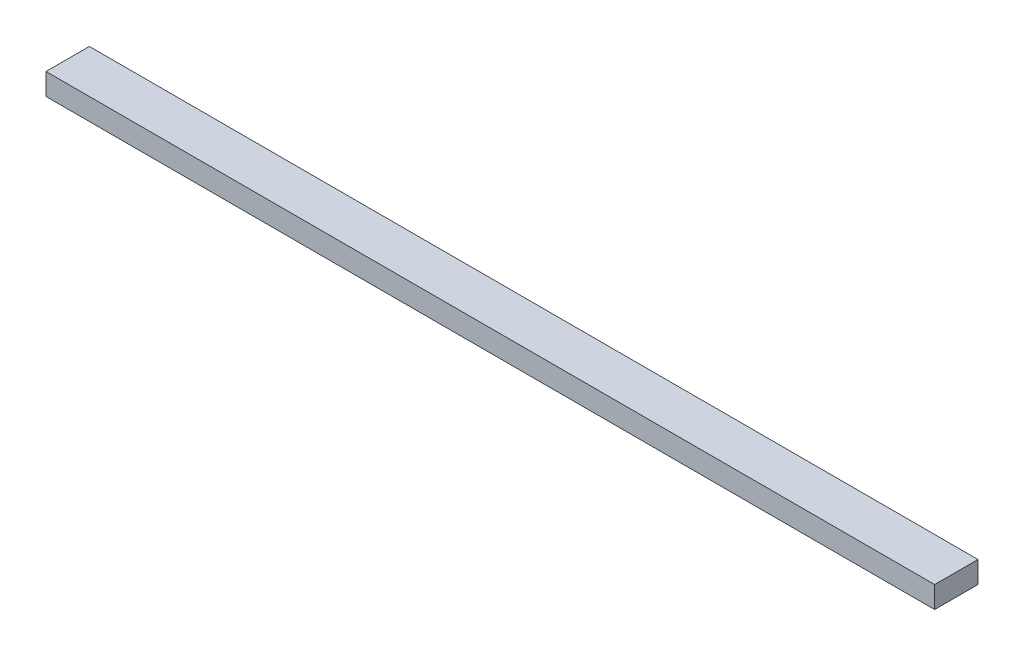
from build123d import *

# Parameters (mm, degrees)
SKETCH1_W           = 410
SKETCH1_H           = 20
BOSS_EXTRUDE1_DEPTH = 10


with BuildPart() as part:
    # Sketch1 → Boss-Extrude1 (new body)
    with BuildSketch(Plane(origin=(0, 0, 0), x_dir=(1, 0, 0), z_dir=(0, 1, 0))):
        Rectangle(SKETCH1_W, SKETCH1_H)
    extrude(amount=BOSS_EXTRUDE1_DEPTH)


solid = part.part
